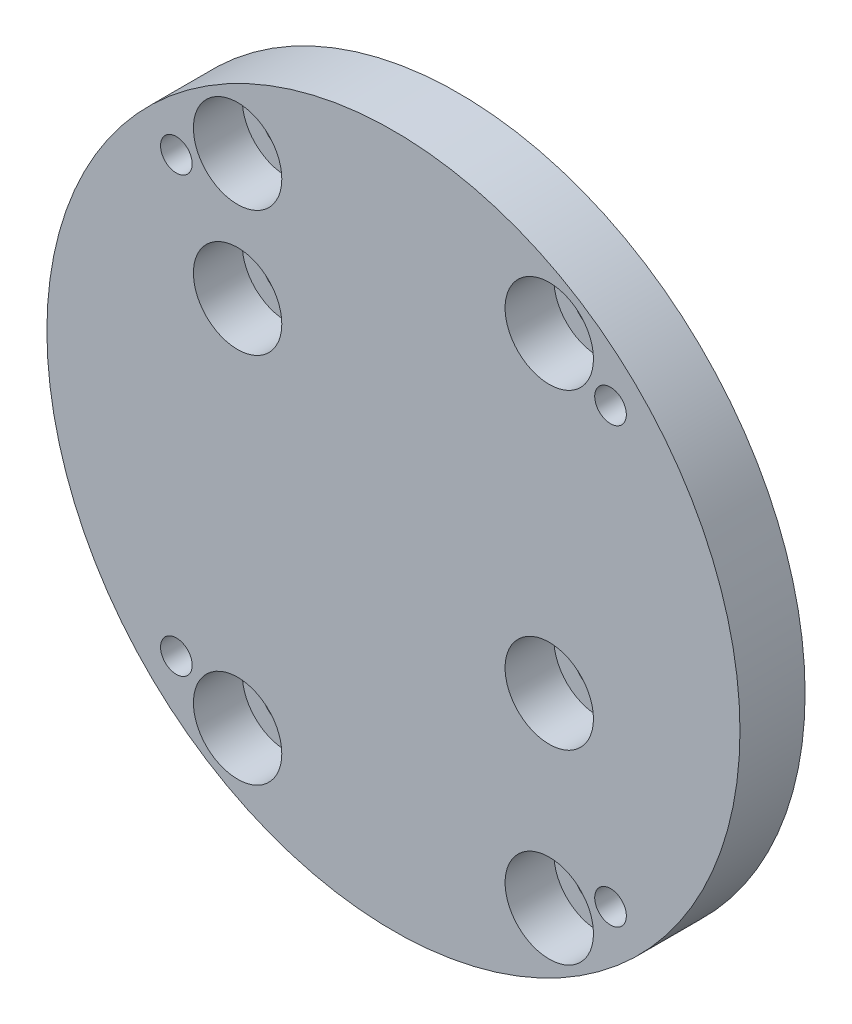
from build123d import *

# Parameters (mm, degrees)
SKETCH_1_R                    = 74.5
EXTRUDE_1_DEPTH               = 14
HOLE_WIZARD_M10_1_D           = 11
HOLE_WIZARD_M10_1_CBORE_D     = 19
HOLE_WIZARD_M10_1_CBORE_DEPTH = 10.5
HOLE_WIZARD_M8_1_D            = 6.8
PATTERN_CIRCULAR_1_COUNT      = 4


with BuildPart() as part:
    # 草图1 → 凸台-拉伸1 (new body)
    with BuildSketch(Plane.XY):
        Circle(SKETCH_1_R)
    extrude(amount=EXTRUDE_1_DEPTH)

    # M10 六角头螺栓的柱形沉头孔1 (through all)
    with Locations(Plane.XY.offset(14)):
        with Locations((-33.5, 26.5), (-33.5, -53.5), (33.5, -53.5), (33.5, -13.5), (33.5, 53.5), (-33.5, 53.5)):
            CounterBoreHole(HOLE_WIZARD_M10_1_D / 2, HOLE_WIZARD_M10_1_CBORE_D / 2, HOLE_WIZARD_M10_1_CBORE_DEPTH)

    # M8 螺纹孔的螺纹孔钻头1 (through all)
    with Locations(Plane.XY.offset(14)):
        with Locations((46.669047558, 46.669047558)):
            hole_wizard_m8_1 = Hole(HOLE_WIZARD_M8_1_D / 2)

    # 阵列(圆周)1: M8 螺纹孔的螺纹孔钻头1 ×4 about axis
    pattern_circular_1_axis = Axis((0, 0, 0), (0, 0, 1))
    for i in range(1, PATTERN_CIRCULAR_1_COUNT):
        add(hole_wizard_m8_1.rotate(pattern_circular_1_axis, i * 360 / PATTERN_CIRCULAR_1_COUNT), mode=Mode.SUBTRACT)


solid = part.part
